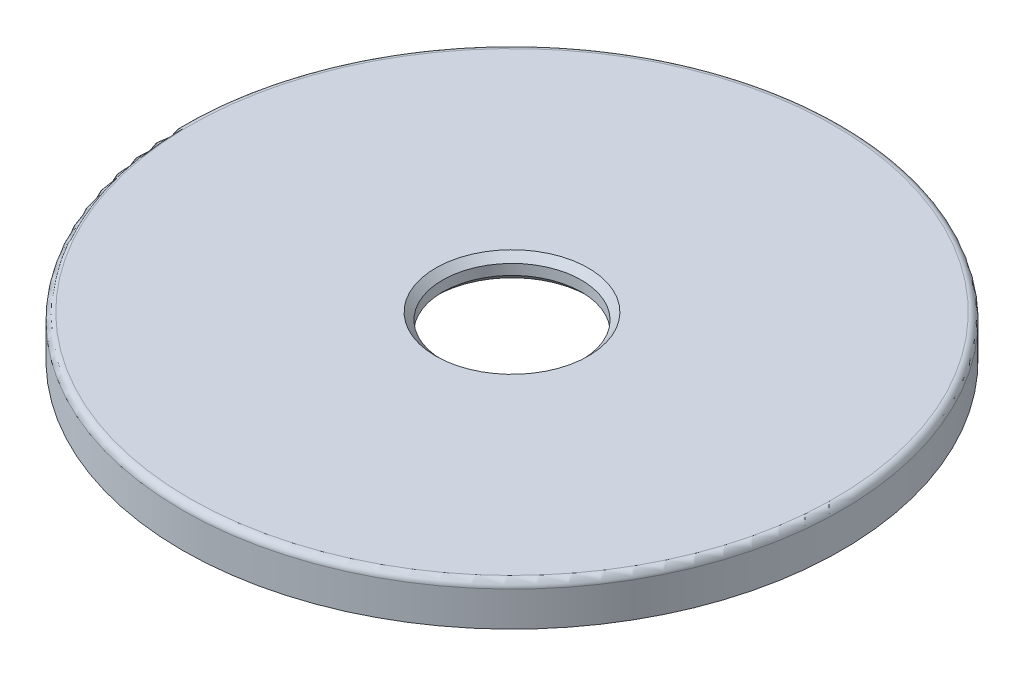
from build123d import *

# Parameters (mm, degrees)
SKETCH1_R           = 47.5
BOSS_EXTRUDE1_DEPTH = 2
SKETCH2_R           = 42.5
BOSS_EXTRUDE2_DEPTH = 1.5
BOSS_EXTRUDE2_TAPER = 2
SKETCH5_R           = 10
CUT_EXTRUDE1_DEPTH  = 4
CHAMFER1_SIZE       = 1
SKETCH7_R           = 47.5
SKETCH7_R_2         = 45.6
BOSS_EXTRUDE3_DEPTH = 4
FILLET2_R           = 1


with BuildPart() as part:
    # Sketch1 → Boss-Extrude1 (new body)
    with BuildSketch(Plane(origin=(0, 0, 0), x_dir=(1, 0, 0), z_dir=(0, 1, 0))):
        Circle(SKETCH1_R)
    extrude(amount=BOSS_EXTRUDE1_DEPTH)

    # Sketch2 → Boss-Extrude2 (add)
    with BuildSketch(Plane.XZ):
        Circle(SKETCH2_R)
    extrude(amount=BOSS_EXTRUDE2_DEPTH, taper=BOSS_EXTRUDE2_TAPER)

    # Sketch5 → Cut-Extrude1 (cut)
    with BuildSketch(Plane(origin=(0, 2, 0), x_dir=(1, 0, 0), z_dir=(0, 1, 0))):
        Circle(SKETCH5_R)
    extrude(amount=-CUT_EXTRUDE1_DEPTH, mode=Mode.SUBTRACT)

    # Chamfer1
    chamfer1_edges = [part.edges().sort_by_distance(p)[0] for p in [
        (-10, -1.5, 0),
        (-10, 2, 0),
    ]]
    chamfer(chamfer1_edges, length=CHAMFER1_SIZE)

    # Sketch7 → Boss-Extrude3 (add)
    with BuildSketch(Plane.XZ):
        Circle(SKETCH7_R)
        Circle(SKETCH7_R_2, mode=Mode.SUBTRACT)
    extrude(amount=BOSS_EXTRUDE3_DEPTH)

    # Fillet2
    fillet2_edges = [part.edges().sort_by_distance(p)[0] for p in [
        (-47.5, 2, 0),
    ]]
    fillet(fillet2_edges, radius=FILLET2_R)


solid = part.part
